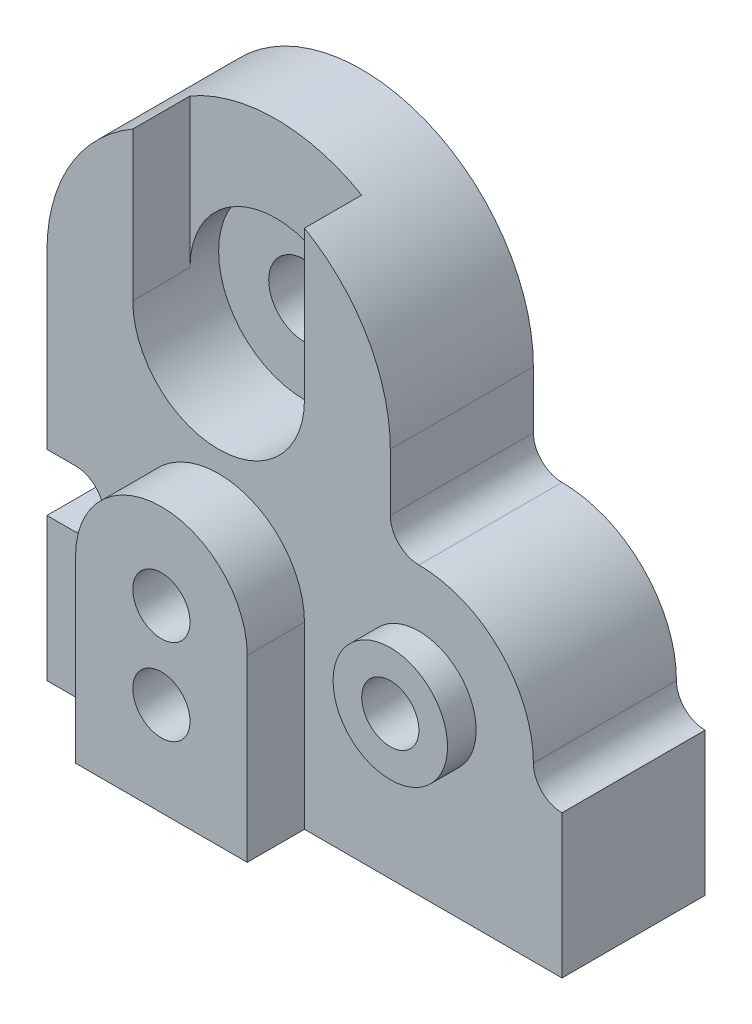
from build123d import *

# Parameters (mm, degrees)
SKETCH1_R           = 1.25
SKETCH1_R_2         = 0.5
SKETCH1_R_3         = 1
BOSS_EXTRUDE1_DEPTH = 5
SKETCH2_R           = 2
CUT_EXTRUDE1_DEPTH  = 2
CUT_EXTRUDE2_DEPTH  = 2
BOSS_EXTRUDE2_DEPTH = 2
SKETCH5_R           = 2
SKETCH5_R_2         = 1
BOSS_EXTRUDE3_DEPTH = 1
SKETCH6_R           = 1.25
BOSS_EXTRUDE4_DEPTH = 1
SKETCH7_R           = 1
CUT_EXTRUDE3_DEPTH  = 3
CUT_EXTRUDE4_DEPTH  = 2
SKETCH9_R           = 3
CUT_EXTRUDE5_DEPTH  = 1
SKETCH10_R          = 1
CUT_EXTRUDE6_DEPTH  = 4


with BuildPart() as part:
    # Sketch1 → Boss-Extrude1 (new body)
    with BuildSketch(Plane.XY):
        with BuildLine():
            Line((0, 0), (18, 0))
            Line((18, 0), (18, 5))
            ThreePointArc((18, 5), (17.292893219, 5.292893219), (17, 6))
            ThreePointArc((17, 6), (15.828427125, 8.828427125), (13, 10))
            ThreePointArc((13, 10), (12.292893219, 10.292893219), (12, 11))
            Line((12, 11), (12, 13))
            ThreePointArc((12, 13), (6, 19), (0, 13))
            Line((0, 13), (0, 0))
        make_face()
        with Locations((6, 13)):
            Circle(SKETCH1_R, mode=Mode.SUBTRACT)
        with Locations((1, 6)):
            Circle(SKETCH1_R_2, mode=Mode.SUBTRACT)
        with Locations((13, 6)):
            Circle(SKETCH1_R_3, mode=Mode.SUBTRACT)
    extrude(amount=BOSS_EXTRUDE1_DEPTH)

    # Sketch2 → Cut-Extrude1 (cut)
    with BuildSketch(Plane(origin=(0, 0, 0), x_dir=(-1, 0, 0), z_dir=(0, 0, -1))):
        with Locations((-13, 6)):
            Circle(SKETCH2_R)
    extrude(amount=-CUT_EXTRUDE1_DEPTH, mode=Mode.SUBTRACT)

    # Sketch3 → Cut-Extrude2 (cut)
    with BuildSketch(Plane.XY.offset(5)):
        with BuildLine():
            Line((3, 13), (3, 19.864652962))
            ThreePointArc((3, 19.864652962), (6, 22.864652962), (9, 19.864652962))
            Line((9, 19.864652962), (9, 13))
            ThreePointArc((9, 13), (6, 10), (3, 13))
        make_face()
    extrude(amount=-CUT_EXTRUDE2_DEPTH, mode=Mode.SUBTRACT)

    # Sketch4 → Boss-Extrude2 (add)
    with BuildSketch(Plane.XY.offset(5)):
        with BuildLine():
            Line((9, 6.266637239), (9, 0))
            Line((9, 0), (3, 0))
            Line((3, 0), (3, 6.266637239))
            ThreePointArc((3, 6.266637239), (6, 9.266637239), (9, 6.266637239))
        make_face()
    extrude(amount=BOSS_EXTRUDE2_DEPTH)

    # Sketch5 → Boss-Extrude3 (add)
    with BuildSketch(Plane.XY.offset(5)):
        with Locations((13, 6)):
            Circle(SKETCH5_R)
        with Locations((13, 6)):
            Circle(SKETCH5_R_2, mode=Mode.SUBTRACT)
    extrude(amount=BOSS_EXTRUDE3_DEPTH)

    # Sketch6 → Boss-Extrude4 (add)
    with BuildSketch(Plane(origin=(0, 0, 0), x_dir=(-1, 0, 0), z_dir=(0, 0, -1))):
        with BuildLine():
            ThreePointArc((-9, 13), (-6, 10), (-3, 13))
            ThreePointArc((-3, 13), (-6, 16), (-9, 13))
        make_face()
        with Locations((-6, 13)):
            Circle(SKETCH6_R, mode=Mode.SUBTRACT)
    extrude(amount=BOSS_EXTRUDE4_DEPTH)

    # Sketch7 → Cut-Extrude3 (cut)
    with BuildSketch(Plane.XY.offset(7)):
        with Locations((6, 6.266637239)):
            Circle(SKETCH7_R)
        with Locations((6, 3.266637239)):
            Circle(SKETCH7_R)
    extrude(amount=-CUT_EXTRUDE3_DEPTH, mode=Mode.SUBTRACT)

    # Sketch8 → Cut-Extrude4 (cut)
    with BuildSketch(Plane.XY.offset(5)):
        with BuildLine():
            Line((1, 5), (-1.045150713, 5))
            ThreePointArc((-1.045150713, 5), (-2.045150713, 6), (-1.045150713, 7))
            Line((-1.045150713, 7), (1, 7))
            ThreePointArc((1, 7), (2, 6), (1, 5))
        make_face()
    extrude(amount=-CUT_EXTRUDE4_DEPTH, mode=Mode.SUBTRACT)

    # Sketch9 → Cut-Extrude5 (cut)
    with BuildSketch(Plane.XY.offset(3)):
        with Locations((6, 13)):
            Circle(SKETCH9_R)
    extrude(amount=-CUT_EXTRUDE5_DEPTH, mode=Mode.SUBTRACT)

    # Sketch10 → Cut-Extrude6 (cut)
    with BuildSketch(Plane.XY.offset(4)):
        with Locations((6, 3.266637239)):
            Circle(SKETCH10_R)
    extrude(amount=-CUT_EXTRUDE6_DEPTH, mode=Mode.SUBTRACT)


solid = part.part
